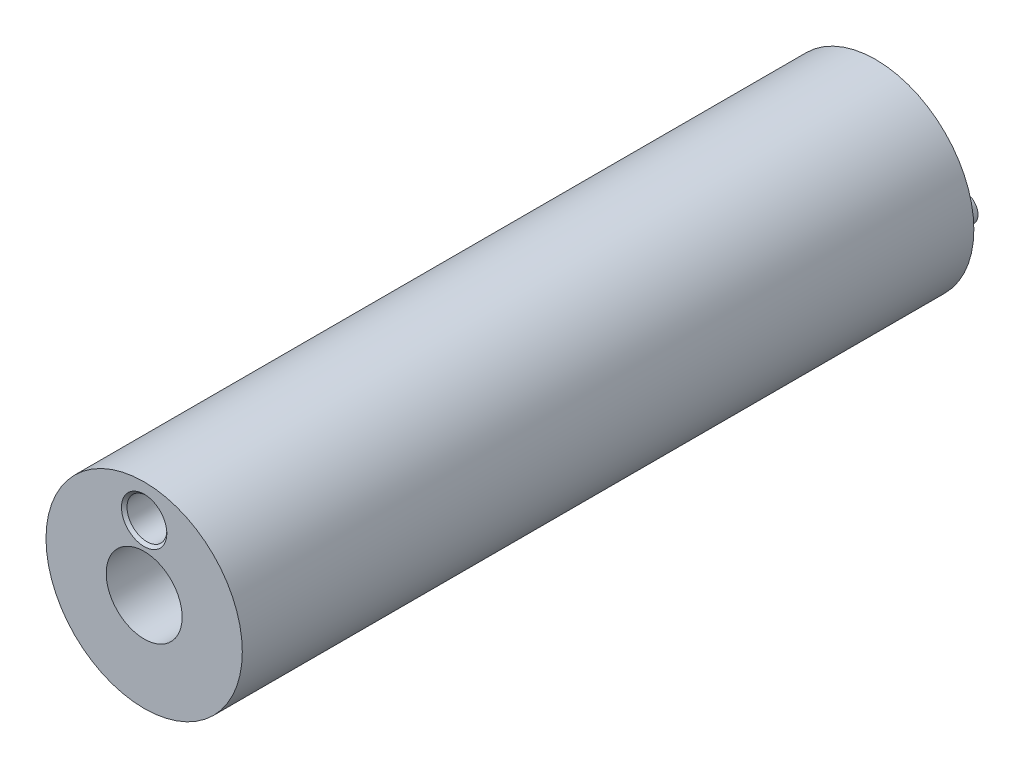
from build123d import *

# Parameters (mm, degrees)
SKETCH_1_R      = 10.6
SKETCH_1_R_2    = 2.15
SKETCH_1_R_3    = 4.1
EXTRUDE_1_DEPTH = 79
SKETCH_2_R      = 1.45
EXTRUDE_2_DEPTH = 1.6
CHAMFER_1_SIZE  = 0.3


with BuildPart() as part:
    # 草图1 → 凸台-拉伸1 (new body)
    with BuildSketch(Plane.XY):
        Circle(SKETCH_1_R)
        with Locations((0, 7)):
            Circle(SKETCH_1_R_2, mode=Mode.SUBTRACT)
        Circle(SKETCH_1_R_3, mode=Mode.SUBTRACT)
    extrude(amount=EXTRUDE_1_DEPTH)

    # 草图2 → 凸台-拉伸2 (add)
    with BuildSketch(Plane.XY):
        with Locations((-8, 0)):
            Circle(SKETCH_2_R)
        with Locations((8, 0)):
            Circle(SKETCH_2_R)
    extrude(amount=-EXTRUDE_2_DEPTH)

    # 倒角1
    chamfer_1_edges = [part.edges().sort_by_distance(p)[0] for p in [
        (-2.15, 7, 0),
        (-2.15, 7, 79),
    ]]
    chamfer(chamfer_1_edges, length=CHAMFER_1_SIZE)


solid = part.part
